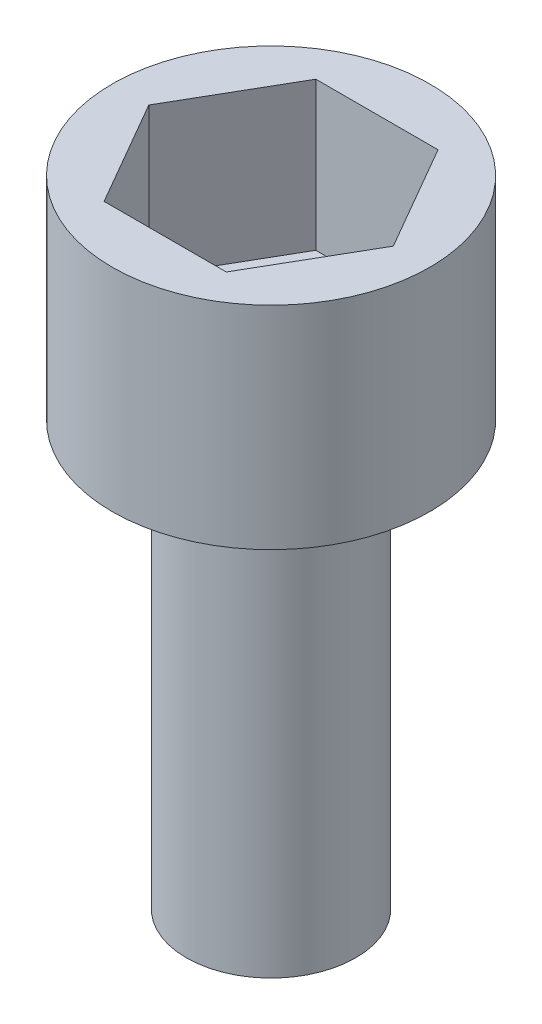
from build123d import *

# Parameters (mm, degrees)
SKETCH1_R           = 4
BOSS_EXTRUDE1_DEPTH = 20
SKETCH2_R           = 7.5
BOSS_EXTRUDE2_DEPTH = 3
SKETCH3_R           = 7.5
BOSS_EXTRUDE3_DEPTH = 7


with BuildPart() as part:
    # Sketch1 → Boss-Extrude1 (new body)
    with BuildSketch(Plane(origin=(0, 0, 0), x_dir=(1, 0, 0), z_dir=(0, 1, 0))):
        Circle(SKETCH1_R)
    extrude(amount=BOSS_EXTRUDE1_DEPTH)

    # Sketch2 → Boss-Extrude2 (add)
    with BuildSketch(Plane(origin=(0, 20, 0), x_dir=(1, 0, 0), z_dir=(0, 1, 0))):
        Circle(SKETCH2_R)
    extrude(amount=BOSS_EXTRUDE2_DEPTH)

    # Sketch3 → Boss-Extrude3 (add)
    with BuildSketch(Plane(origin=(0, 23, 0), x_dir=(1, 0, 0), z_dir=(0, 1, 0))):
        Circle(SKETCH3_R)
        Polygon((5.773502692, 0), (2.886751346, 5), (-2.886751346, 5), (-5.773502692, 0), (-2.886751346, -5), (2.886751346, -5), align=None, mode=Mode.SUBTRACT)
    extrude(amount=BOSS_EXTRUDE3_DEPTH)


solid = part.part
